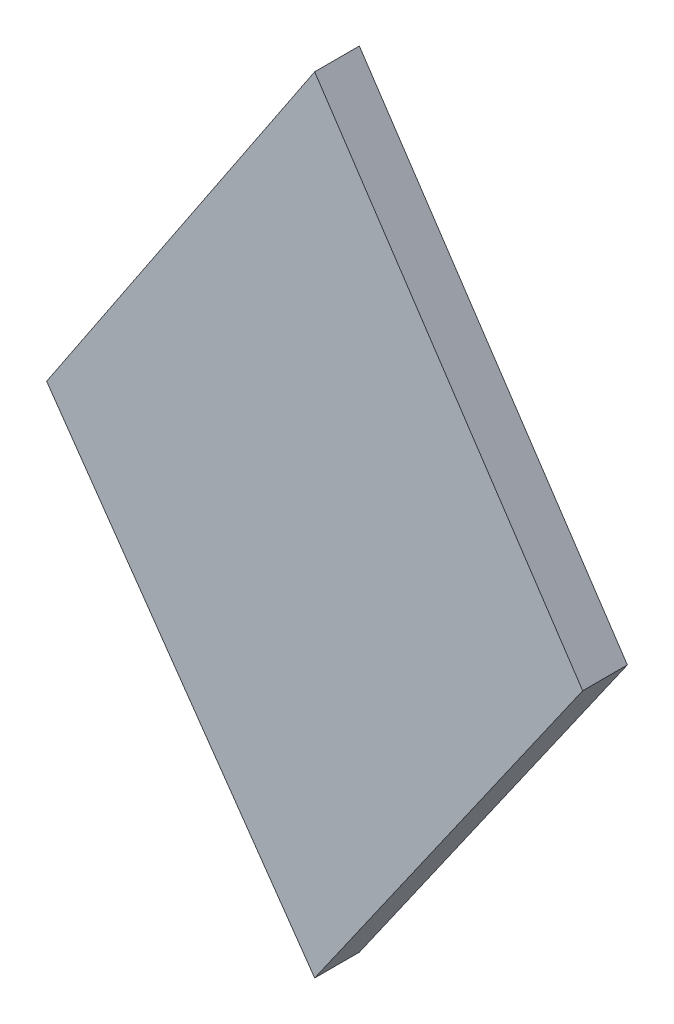
from build123d import *

# Parameters (mm, degrees)
BOSS_EXTRUDE1_DEPTH = 5


with BuildPart() as part:
    # Sketch1 → Boss-Extrude1 (new body)
    with BuildSketch(Plane.XY):
        Polygon((0, 45), (30, 0), (0, -42.844440202), (-30, 0), align=None)
    extrude(amount=BOSS_EXTRUDE1_DEPTH)


solid = part.part
